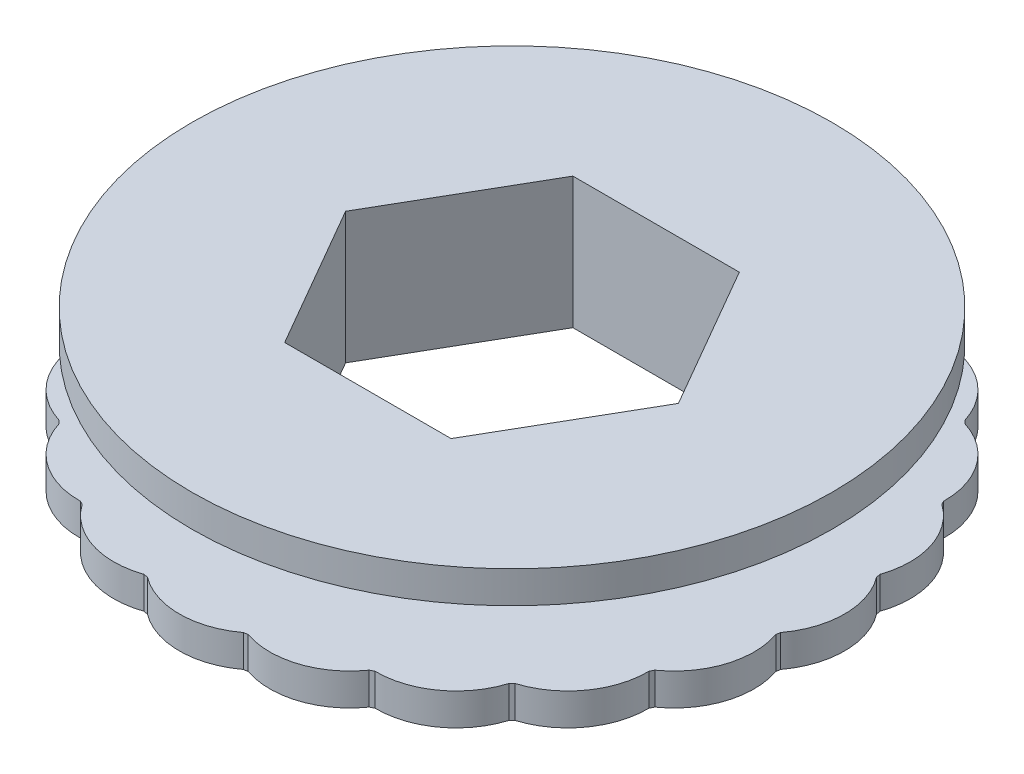
from build123d import *

# Parameters (mm, degrees)
BOSS_EXTRUDE1_DEPTH     = 0.5
CIRPATTERN3_COUNT       = 20
CUT_EXTRUDE1_DEPTH      = 1
CUT_EXTRUDE1_DEPTH_BACK = 3.05


with BuildPart() as part:
    # Sketch1 → Revolve1 (revolve)
    with BuildSketch(Plane(origin=(0, 0, 0), x_dir=(0, 0, -1), z_dir=(1, 0, 0))):
        Polygon((-3.5, 0.525), (-3.5, -0.525), (-5, -0.525), (-5, -1.025), (0, -1.025), (0, -0.525), (0, 0.525), (0, 1.025), (-5, 1.025), (-5, 0.525), align=None)
    revolve(axis=Axis((0, 0, 0), (0, -1, 0)))

    # Sketch3 → Boss-Extrude1 (add)
    with BuildSketch(Plane.XZ.offset(1.025)):
        with BuildLine():
            ThreePointArc((-0.75, 4.943429983), (0, 5.193429983), (0.75, 4.943429983))
            ThreePointArc((0.75, 4.943429983), (0, 5), (-0.75, 4.943429983))
        make_face()
    boss_extrude1 = extrude(amount=-BOSS_EXTRUDE1_DEPTH)

    # CirPattern3: Boss-Extrude1 ×20 about axis
    cirpattern3_axis = Axis((0, 0, 0), (0, 1, 0))
    for i in range(1, CIRPATTERN3_COUNT):
        add(boss_extrude1.rotate(cirpattern3_axis, i * 360 / CIRPATTERN3_COUNT))

    # Sketch4 → Cut-Extrude1 (cut, two sides)
    with BuildSketch(Plane(origin=(0, 1.025, 0), x_dir=(1, 0, 0), z_dir=(0, 1, 0))) as cut_extrude1_sk:
        Polygon((1.299038106, 2.25), (-1.299038106, 2.25), (-2.598076211, 0), (-1.299038106, -2.25), (1.299038106, -2.25), (2.598076211, 0), align=None)
    extrude(amount=CUT_EXTRUDE1_DEPTH, mode=Mode.SUBTRACT)
    extrude(cut_extrude1_sk.sketch, amount=-CUT_EXTRUDE1_DEPTH_BACK, mode=Mode.SUBTRACT)


solid = part.part
